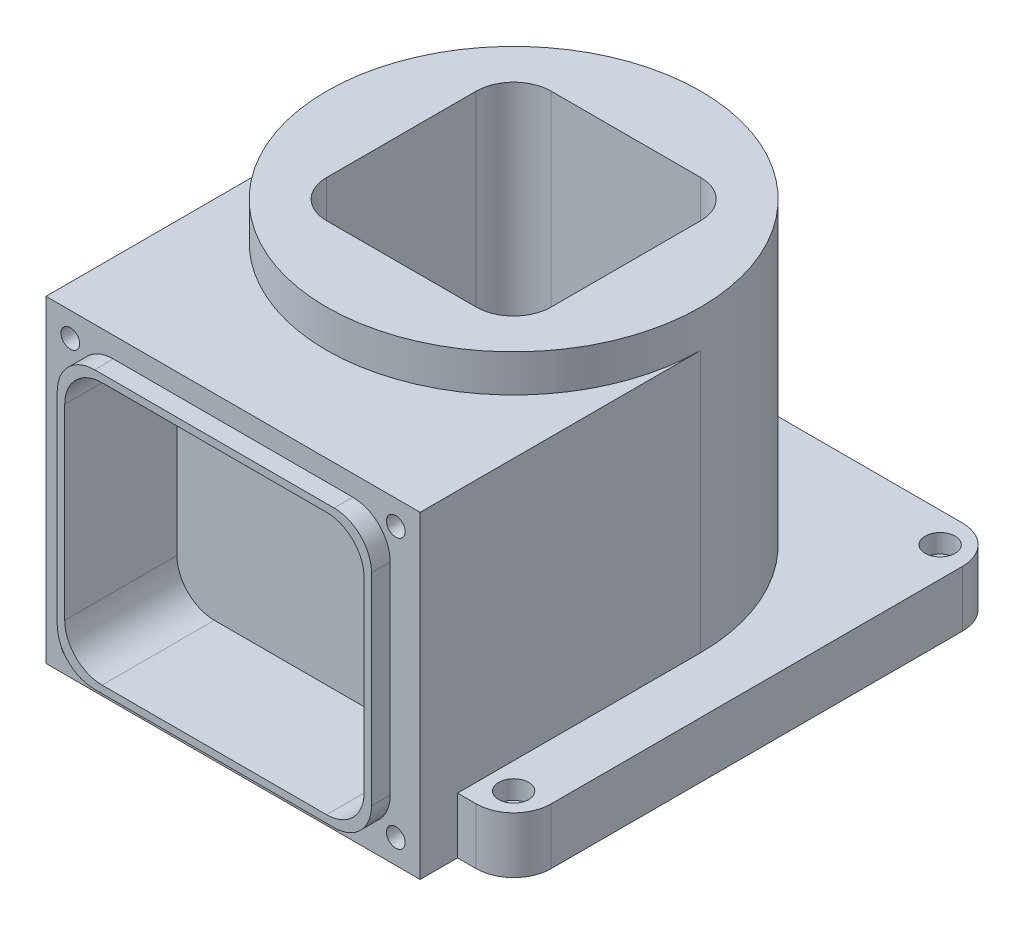
from build123d import *

# Parameters (mm, degrees)
SKETCH1_W           = 130
SKETCH1_H           = 130
BOSS_EXTRUDE1_DEPTH = 15
SKETCH2_R           = 50
BOSS_EXTRUDE2_DEPTH = 80
SKETCH3_W           = 75
SKETCH3_H           = 85
BOSS_EXTRUDE3_DEPTH = 50
CUT_EXTRUDE2_DEPTH  = 60
CUT_EXTRUDE4_DEPTH  = 25
SKETCH6_R           = 2.5
CUT_EXTRUDE5_DEPTH  = 35
FILLET1_R           = 10
BOSS_EXTRUDE5_DEPTH = 5
SKETCH8_R           = 2.5
CUT_EXTRUDE6_DEPTH  = 16
SKETCH9_R           = 4
CUT_EXTRUDE7_DEPTH  = 5


with BuildPart() as part:
    # Sketch1 → Boss-Extrude1 (new body)
    with BuildSketch(Plane(origin=(0, 0, 0), x_dir=(1, 0, 0), z_dir=(0, 1, 0))):
        Rectangle(SKETCH1_W, SKETCH1_H)
    extrude(amount=BOSS_EXTRUDE1_DEPTH)

    # Sketch2 → Boss-Extrude2 (add)
    with BuildSketch(Plane(origin=(0, 15, 0), x_dir=(1, 0, 0), z_dir=(0, 1, 0))):
        Circle(SKETCH2_R)
    extrude(amount=BOSS_EXTRUDE2_DEPTH)

    # Sketch3 → Boss-Extrude3 (add, symmetric)
    with BuildSketch(Plane(origin=(0, 0, 0), x_dir=(0, 0, -1), z_dir=(1, 0, 0))):
        with Locations((-37.5, 42.5)):
            Rectangle(SKETCH3_W, SKETCH3_H)
    extrude(amount=BOSS_EXTRUDE3_DEPTH, both=True)

    # Sketch4 → Cut-Extrude2 (cut)
    with BuildSketch(Plane(origin=(0, 95, 0), x_dir=(1, 0, 0), z_dir=(0, 1, 0))):
        with BuildLine():
            Line((-20, 30), (20, 30))
            ThreePointArc((20, 30), (27.071067812, 27.071067812), (30, 20))
            Line((30, 20), (30, -20))
            ThreePointArc((30, -20), (27.071067812, -27.071067812), (20, -30))
            Line((20, -30), (-20, -30))
            ThreePointArc((-20, -30), (-27.071067812, -27.071067812), (-30, -20))
            Line((-30, -20), (-30, 20))
            ThreePointArc((-30, 20), (-27.071067812, 27.071067812), (-20, 30))
        make_face()
    extrude(amount=-CUT_EXTRUDE2_DEPTH, mode=Mode.SUBTRACT)

    # Sketch5 → Cut-Extrude4 (cut)
    with BuildSketch(Plane.XY.offset(75)):
        with BuildLine():
            Line((-30, 77.5), (30, 77.5))
            ThreePointArc((30, 77.5), (37.071067812, 74.571067812), (40, 67.5))
            Line((40, 67.5), (40, 17.5))
            ThreePointArc((40, 17.5), (37.071067812, 10.428932188), (30, 7.5))
            Line((30, 7.5), (-30, 7.5))
            ThreePointArc((-30, 7.5), (-37.071067812, 10.428932188), (-40, 17.5))
            Line((-40, 17.5), (-40, 67.5))
            ThreePointArc((-40, 67.5), (-37.071067812, 74.571067812), (-30, 77.5))
        make_face()
    extrude(amount=-CUT_EXTRUDE4_DEPTH, mode=Mode.SUBTRACT)

    # Sketch6 → Cut-Extrude5 (cut)
    with BuildSketch(Plane.XY.offset(75)):
        with Locations((-43.5, 78.5)):
            Circle(SKETCH6_R)
        with Locations((43.5, 78.5)):
            Circle(SKETCH6_R)
        with Locations((43.5, 6.5)):
            Circle(SKETCH6_R)
        with Locations((-43.5, 6.5)):
            Circle(SKETCH6_R)
    extrude(amount=-CUT_EXTRUDE5_DEPTH, mode=Mode.SUBTRACT)

    # Fillet1
    fillet1_edges = [part.edges().sort_by_distance(p)[0] for p in [
        (65, 7.5, 65),
        (-65, 7.5, 65),
        (-65, 7.5, -65),
        (65, 7.5, -65),
    ]]
    fillet(fillet1_edges, radius=FILLET1_R)

    # Sketch7 → Boss-Extrude5 (add)
    with BuildSketch(Plane.XY.offset(75)):
        with BuildLine():
            Line((-32, 79.5), (32, 79.5))
            ThreePointArc((32, 79.5), (39.071067812, 76.571067812), (42, 69.5))
            Line((42, 69.5), (42, 15.5))
            ThreePointArc((42, 15.5), (39.071067812, 8.428932188), (32, 5.5))
            Line((32, 5.5), (-32, 5.5))
            ThreePointArc((-32, 5.5), (-39.071067812, 8.428932188), (-42, 15.5))
            Line((-42, 15.5), (-42, 69.5))
            ThreePointArc((-42, 69.5), (-39.071067812, 76.571067812), (-32, 79.5))
        make_face()
        with BuildLine():
            Line((-30, 77.5), (30, 77.5))
            ThreePointArc((30, 77.5), (37.071067812, 74.571067812), (40, 67.5))
            Line((40, 67.5), (40, 17.5))
            ThreePointArc((40, 17.5), (37.071067812, 10.428932188), (30, 7.5))
            Line((30, 7.5), (-30, 7.5))
            ThreePointArc((-30, 7.5), (-37.071067812, 10.428932188), (-40, 17.5))
            Line((-40, 17.5), (-40, 67.5))
            ThreePointArc((-40, 67.5), (-37.071067812, 74.571067812), (-30, 77.5))
        make_face(mode=Mode.SUBTRACT)
    extrude(amount=BOSS_EXTRUDE5_DEPTH)

    # Sketch8 → Cut-Extrude6 (cut, through all)
    with BuildSketch(Plane(origin=(0, 15, 0), x_dir=(1, 0, 0), z_dir=(0, 1, 0))):
        with Locations((-57, 57)):
            Circle(SKETCH8_R)
        with Locations((-57, -57)):
            Circle(SKETCH8_R)
        with Locations((57, -57)):
            Circle(SKETCH8_R)
        with Locations((57, 57)):
            Circle(SKETCH8_R)
    extrude(amount=-CUT_EXTRUDE6_DEPTH, mode=Mode.SUBTRACT)

    # Sketch9 → Cut-Extrude7 (cut)
    with BuildSketch(Plane(origin=(0, 15, 0), x_dir=(1, 0, 0), z_dir=(0, 1, 0))):
        with Locations((-57, 57)):
            Circle(SKETCH9_R)
        with Locations((57, 57)):
            Circle(SKETCH9_R)
        with Locations((-57, -57)):
            Circle(SKETCH9_R)
        with Locations((57, -57)):
            Circle(SKETCH9_R)
    extrude(amount=-CUT_EXTRUDE7_DEPTH, mode=Mode.SUBTRACT)


solid = part.part
